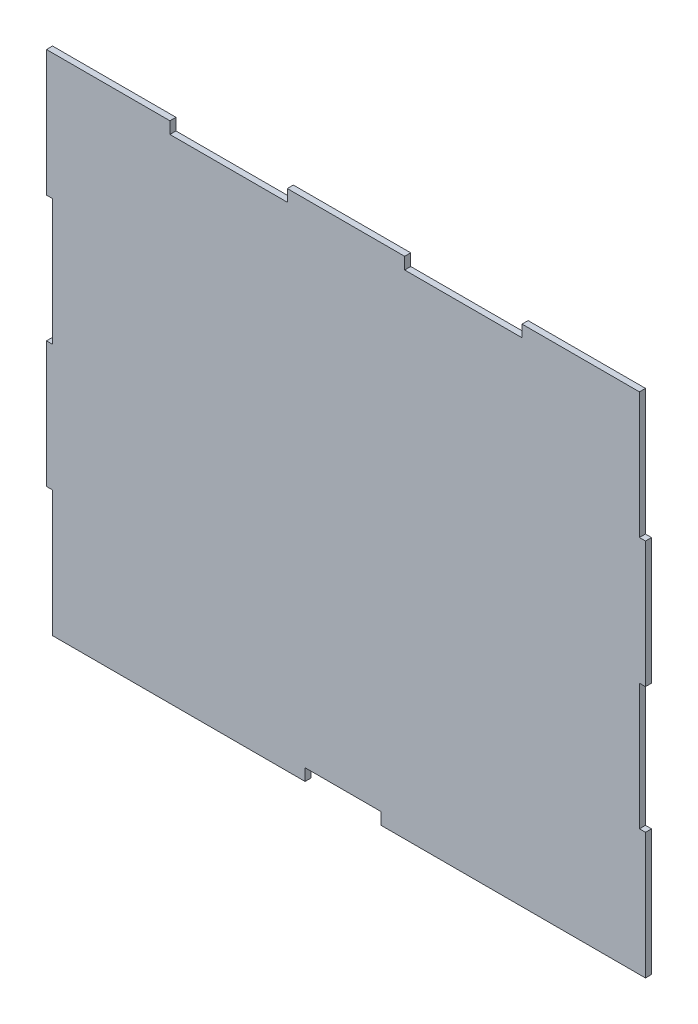
from build123d import *

# Parameters (mm, degrees)
BOSS_EXTRUDE1_DEPTH = 3.048


with BuildPart() as part:
    # Sketch1 → Boss-Extrude1 (new body)
    with BuildSketch(Plane.XY):
        Polygon((127.127, 0), (127.127, 5.9944), (165.227, 5.9944), (165.227, 0), (298.45, 0), (298.45, 63.5), (295.402, 63.5), (295.402, 126.981711342), (298.45, 126.981711342), (298.45, 190.481711342), (295.402, 190.481711342), (295.402, 253.981711342), (236.3216, 253.981711342), (236.3216, 248.012711342), (177.2412, 248.012711342), (177.2412, 253.981711342), (118.1608, 253.981711342), (118.1608, 248.012711342), (59.0804, 248.012711342), (59.0804, 253.981711342), (-3.048, 253.981711342), (-3.048, 190.5), (0, 190.5), (0, 127), (-3.048, 127), (-3.048, 63.5), (0, 63.5), (0, 0), align=None)
    extrude(amount=BOSS_EXTRUDE1_DEPTH)


solid = part.part
